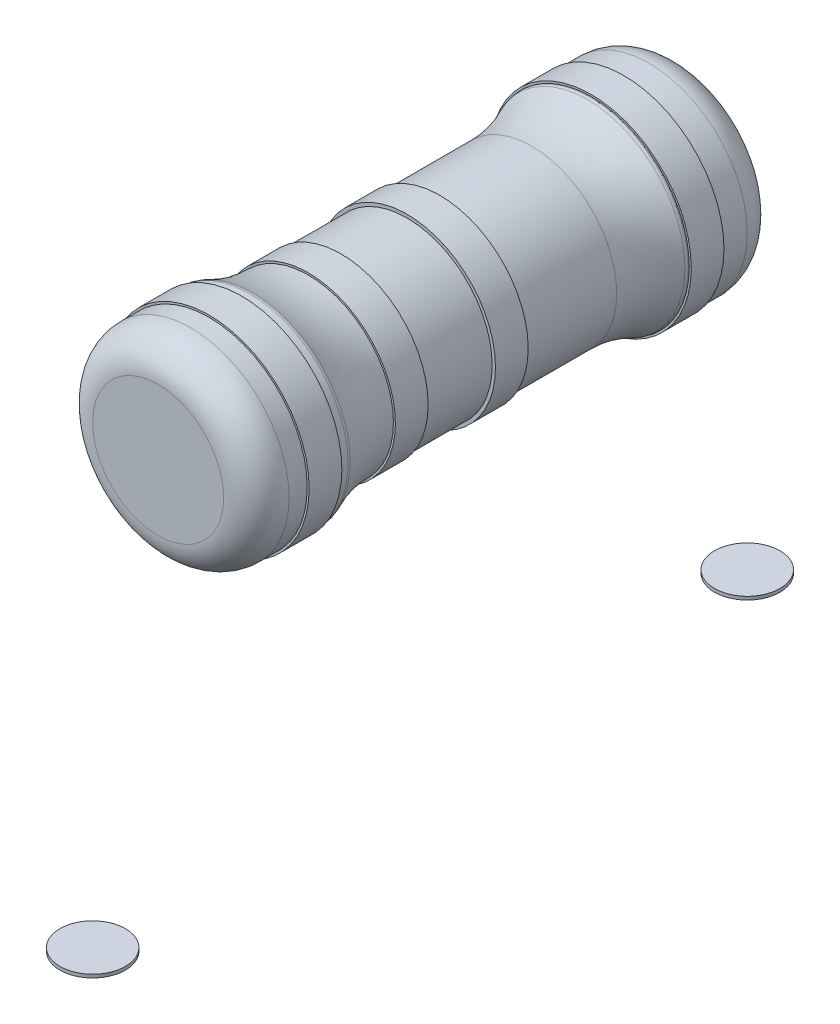
from build123d import *

# Parameters (mm, degrees)
FILLET1_R           = 2
SKETCH2_W           = 0.5
SKETCH2_H           = 0.029991608
SKETCH3_W           = 0.5
SKETCH3_H           = 0.05
SKETCH4_W           = 0.5
SKETCH4_H           = 0.03
SKETCH5_W           = 0.5
SKETCH5_H           = 0.03
SKETCH7_R           = 0.5
BOSS_EXTRUDE1_DEPTH = 0.05
SKETCH12_R          = 0.5
BOSS_EXTRUDE2_DEPTH = 0.05


with BuildPart() as part:
    # Sketch1 → Revolve1 (revolve)
    with BuildSketch(Plane(origin=(0, 0, 0), x_dir=(0, 0, -1), z_dir=(1, 0, 0))):
        with BuildLine():
            Line((2.6, 1.5), (3.5, 1.5))
            ThreePointArc((3.5, 1.5), (3.853553391, 1.353553391), (4, 1))
            Line((4, 1), (4, 0))
            Line((4, 0), (-4, 0))
            Line((-4, 0), (-4, 1))
            ThreePointArc((-4, 1), (-3.853553391, 1.353553391), (-3.5, 1.5))
            Line((-3.5, 1.5), (-2.6, 1.5))
            ThreePointArc((-2.6, 1.5), (-2.529289322, 1.470710678), (-2.5, 1.4))
            Line((-2.5, 1.4), (-2.5, 1.3))
            Line((-2.5, 1.3), (2.5, 1.3))
            Line((2.5, 1.3), (2.5, 1.4))
            ThreePointArc((2.5, 1.4), (2.529289322, 1.470710678), (2.6, 1.5))
        make_face()
    revolve(axis=Axis((0, 0, 30.94688027), (0, 0, -1)))

    # Fillet1
    fillet1_edges = [part.edges().sort_by_distance(p)[0] for p in [
        (0, -1.3, -2.5),
        (0, -1.3, 2.5),
    ]]
    fillet(fillet1_edges, radius=FILLET1_R)

    # Sketch2 → Revolve2 (revolve)
    with BuildSketch(Plane(origin=(0, 0, 0), x_dir=(0, 0, -1), z_dir=(1, 0, 0))):
        with Locations((-1.455572809, 1.314995804)):
            Rectangle(SKETCH2_W, SKETCH2_H)
    revolve(axis=Axis((0, 0, 2.184724067), (0, 0, -1)))

    # Sketch3 → Revolve3 (revolve)
    with BuildSketch(Plane(origin=(0, 0, 0), x_dir=(0, 0, -1), z_dir=(1, 0, 0))):
        with Locations((0.053199548, 1.325)):
            Rectangle(SKETCH3_W, SKETCH3_H)
    revolve(axis=Axis((0, 0, 0.48939527), (0, 0, -1)))

    # Sketch4 → Revolve4 (revolve)
    with BuildSketch(Plane(origin=(0, 0, 0), x_dir=(0, 0, -1), z_dir=(1, 0, 0))):
        with Locations((-2.972757668, 1.515)):
            Rectangle(SKETCH4_W, SKETCH4_H)
    revolve(axis=Axis((0, 0, 0.449237838), (0, 0, -1)))

    # Sketch5 → Revolve5 (revolve)
    with BuildSketch(Plane(origin=(0, 0, 0), x_dir=(0, 0, -1), z_dir=(1, 0, 0))):
        with Locations((2.864549609, 1.515)):
            Rectangle(SKETCH5_W, SKETCH5_H)
    revolve(axis=Axis((0, 0, 0.313399994), (0, 0, -1)))


with BuildPart() as body_2:
    # Sketch7 → Boss-Extrude1 (new body)
    with BuildSketch(Plane(origin=(0, -6, 0), x_dir=(-1, 0, 0), z_dir=(0, 1, 0))):
        with Locations((0, 5)):
            Circle(SKETCH7_R)
    extrude(amount=BOSS_EXTRUDE1_DEPTH)


with BuildPart() as body_3:
    # Sketch12 → Boss-Extrude2 (new body)
    with BuildSketch(Plane(origin=(0, -6, 0), x_dir=(-1, 0, 0), z_dir=(0, 1, 0))):
        with Locations((0, -5)):
            Circle(SKETCH12_R)
    extrude(amount=BOSS_EXTRUDE2_DEPTH)


solid = Compound([part.part, body_2.part, body_3.part])
